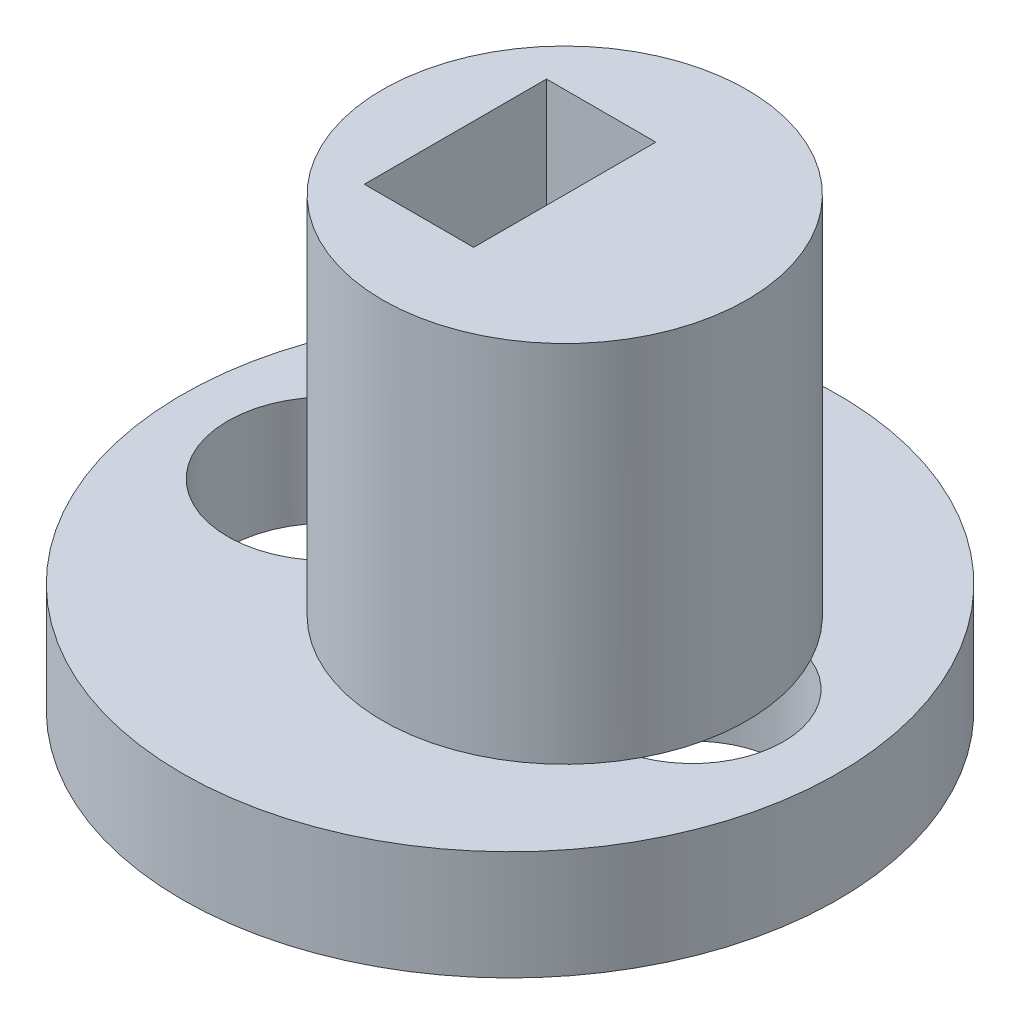
from build123d import *

# Parameters (mm, degrees)
SKETCH1_R           = 9
SKETCH1_R_2         = 2.75
SKETCH1_R_3         = 2.5
BOSS_EXTRUDE1_DEPTH = 3
SKETCH4_R           = 5
SKETCH4_W           = 3
SKETCH4_H           = 5
BOSS_EXTRUDE4_DEPTH = 10


with BuildPart() as part:
    # Sketch1 → Boss-Extrude1 (new body)
    with BuildSketch(Plane(origin=(0, 0, 0), x_dir=(1, 0, 0), z_dir=(0, 1, 0))):
        Circle(SKETCH1_R)
        with Locations((-5, 0.000835232)):
            Circle(SKETCH1_R_2, mode=Mode.SUBTRACT)
        with Locations((5, 0)):
            Circle(SKETCH1_R_3, mode=Mode.SUBTRACT)
    extrude(amount=BOSS_EXTRUDE1_DEPTH)

    # Sketch4 → Boss-Extrude4 (add)
    with BuildSketch(Plane(origin=(0, 3, 0), x_dir=(1, 0, 0), z_dir=(0, 1, 0))):
        with Locations((1.5, 0)):
            Circle(SKETCH4_R)
        Rectangle(SKETCH4_W, SKETCH4_H, mode=Mode.SUBTRACT)
    extrude(amount=BOSS_EXTRUDE4_DEPTH)


solid = part.part
